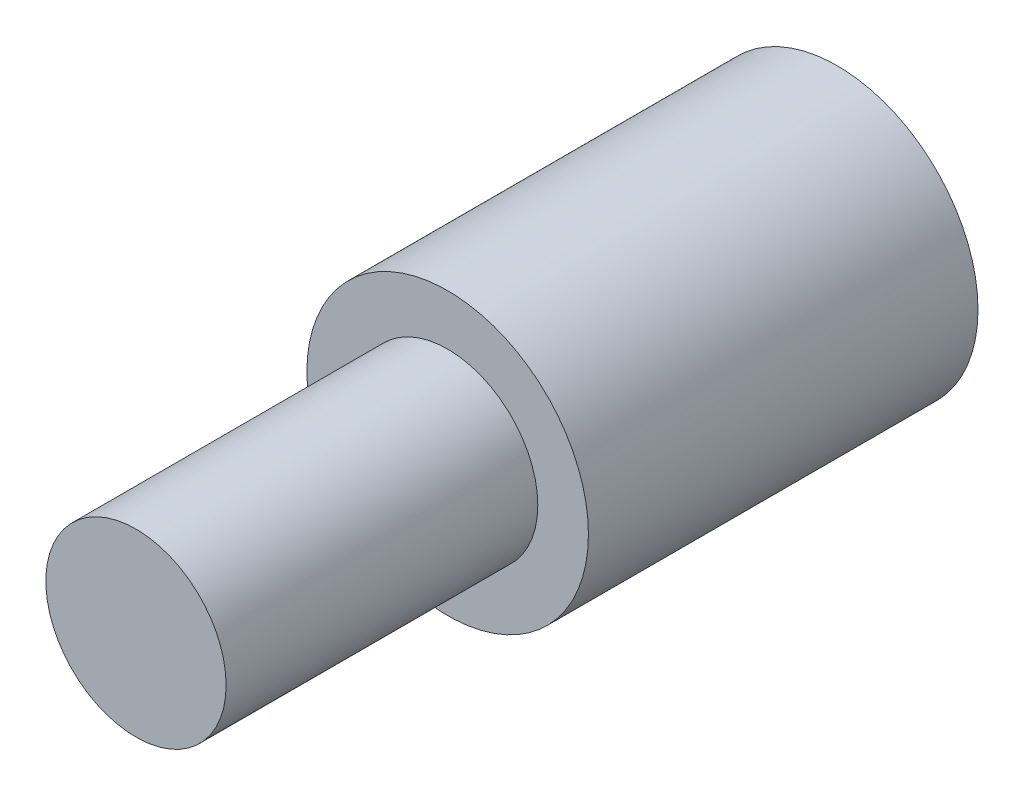
from build123d import *

# Parameters (mm, degrees)
SKETCH2_R           = 21.680023012
BOSS_EXTRUDE1_DEPTH = 60
SKETCH4_R           = 13.88282231
BOSS_EXTRUDE2_DEPTH = 108


with BuildPart() as part:
    # Sketch2 → Boss-Extrude1 (new body)
    with BuildSketch(Plane.XY):
        with Locations((-23.347279537, 22.582502292)):
            Circle(SKETCH2_R)
    extrude(amount=BOSS_EXTRUDE1_DEPTH)

    # Sketch4 → Boss-Extrude2 (add)
    with BuildSketch(Plane.XY):
        with Locations((-23.347279537, 22.582502292)):
            Circle(SKETCH4_R)
    extrude(amount=BOSS_EXTRUDE2_DEPTH)


solid = part.part
